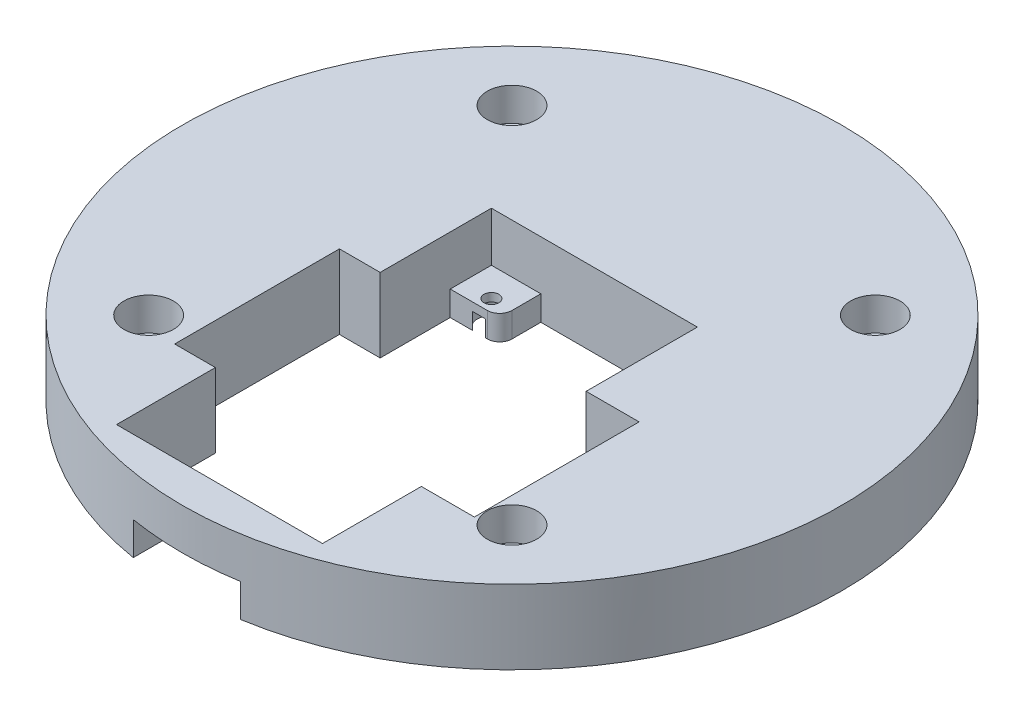
from build123d import *

# Parameters (mm, degrees)
SKETCH1_R                = 40
BOSS_EXTRUDE1_DEPTH      = 8
BOSS_EXTRUDE1_DEPTH_BACK = 1
SKETCH2_W                = 25
SKETCH2_H                = 45.5
CUT_EXTRUDE1_DEPTH       = 6
CUT_EXTRUDE2_DEPTH       = 6
SKETCH4_R                = 3
CUT_EXTRUDE3_DEPTH       = 4
SKETCH5_R                = 1.4
CUT_EXTRUDE4_DEPTH       = 5
CIRPATTERN1_COUNT        = 4
FILLET1_R                = 1.5
SKETCH6_W                = 13
SKETCH6_H                = 8.686825583
CUT_EXTRUDE5_DEPTH       = 4
CUT_EXTRUDE6_START       = -9
SKETCH7_W                = 36.377301766
SKETCH7_H                = 20
CUT_EXTRUDE6_DEPTH       = 9
SKETCH8_R                = 0.9
CUT_EXTRUDE7_DEPTH       = 4
SKETCH9_R                = 1.7
CUT_EXTRUDE10_DEPTH      = 2


with BuildPart() as part:
    # Sketch1 → Boss-Extrude1 (new body, two sides)
    with BuildSketch(Plane(origin=(0, 0, 0), x_dir=(1, 0, 0), z_dir=(0, 1, 0))) as boss_extrude1_sk:
        Circle(SKETCH1_R)
    extrude(amount=BOSS_EXTRUDE1_DEPTH)
    extrude(boss_extrude1_sk.sketch, amount=-BOSS_EXTRUDE1_DEPTH_BACK)

    # Sketch2 → Cut-Extrude1 (cut)
    with BuildSketch(Plane(origin=(0, 8, 0), x_dir=(1, 0, 0), z_dir=(0, 1, 0))):
        with Locations((0, -12.75)):
            Rectangle(SKETCH2_W, SKETCH2_H)
    extrude(amount=-CUT_EXTRUDE1_DEPTH, mode=Mode.SUBTRACT)

    # Sketch3 → Cut-Extrude2 (cut)
    with BuildSketch(Plane(origin=(0, 2, 0), x_dir=(1, 0, 0), z_dir=(0, 1, 0))):
        Polygon((-12.5, 5), (-6.5, 5), (-6.5, 10), (6.5, 10), (6.5, 5), (12.5, 5), (12.5, -30.5), (6.5, -30.5), (6.5, -35.5), (-6.5, -35.5), (-6.5, -30.5), (-12.5, -30.5), align=None)
    extrude(amount=-CUT_EXTRUDE2_DEPTH, mode=Mode.SUBTRACT)

    # Sketch4 → Cut-Extrude3 (cut)
    with BuildSketch(Plane(origin=(0, 8, 0), x_dir=(1, 0, 0), z_dir=(0, 1, 0))):
        with Locations((22.051187962, -22.051187962)):
            Circle(SKETCH4_R)
    cut_extrude3 = extrude(amount=-CUT_EXTRUDE3_DEPTH, mode=Mode.SUBTRACT)

    # Sketch5 → Cut-Extrude4 (cut)
    with BuildSketch(Plane(origin=(0, 4, 0), x_dir=(1, 0, 0), z_dir=(0, 1, 0))):
        with Locations((22.051187962, -22.051187962)):
            Circle(SKETCH5_R)
    cut_extrude4 = extrude(amount=-CUT_EXTRUDE4_DEPTH, mode=Mode.SUBTRACT)

    # CirPattern1: Cut-Extrude3, Cut-Extrude4 ×4 about axis
    cirpattern1_axis = Axis((0, 0, 0), (0, 1, 0))
    for i in range(1, CIRPATTERN1_COUNT):
        add(cut_extrude3.rotate(cirpattern1_axis, i * 360 / CIRPATTERN1_COUNT), mode=Mode.SUBTRACT)
        add(cut_extrude4.rotate(cirpattern1_axis, i * 360 / CIRPATTERN1_COUNT), mode=Mode.SUBTRACT)

    # Fillet1
    fillet1_edges = [part.edges().sort_by_distance(p)[0] for p in [
        (-6.5, 0.5, -5),
        (6.5, 0.5, -5),
        (6.5, 0.5, 30.5),
        (-6.5, 0.5, 30.5),
    ]]
    fillet(fillet1_edges, radius=FILLET1_R)

    # Sketch6 → Cut-Extrude5 (cut)
    with BuildSketch(Plane.XZ.offset(1)):
        with Locations((0, 39.843412792)):
            Rectangle(SKETCH6_W, SKETCH6_H)
    extrude(amount=-CUT_EXTRUDE5_DEPTH, mode=Mode.SUBTRACT)

    # Sketch7 → Cut-Extrude6 (cut)
    with BuildSketch(Plane.XZ.offset(1).offset(CUT_EXTRUDE6_START)):
        with Locations((0.741230287, 13.5)):
            Rectangle(SKETCH7_W, SKETCH7_H)
    extrude(amount=CUT_EXTRUDE6_DEPTH, mode=Mode.SUBTRACT)

    # Sketch8 → Cut-Extrude7 (cut)
    with BuildSketch(Plane(origin=(0, 2, 0), x_dir=(1, 0, 0), z_dir=(0, 1, 0))):
        with Locations((9, -32)):
            Circle(SKETCH8_R)
        with Locations((-9, -32)):
            Circle(SKETCH8_R)
        with Locations((-9, 6.5)):
            Circle(SKETCH8_R)
        with Locations((9, 6.5)):
            Circle(SKETCH8_R)
    extrude(amount=-CUT_EXTRUDE7_DEPTH, mode=Mode.SUBTRACT)

    # Sketch9 → Cut-Extrude10 (cut)
    with BuildSketch(Plane.XZ.offset(1)):
        with Locations((-9, -6.5)):
            Circle(SKETCH9_R)
        with Locations((9, -6.5)):
            Circle(SKETCH9_R)
        with Locations((9, 32)):
            Circle(SKETCH9_R)
        with Locations((-9, 32)):
            Circle(SKETCH9_R)
    extrude(amount=-CUT_EXTRUDE10_DEPTH, mode=Mode.SUBTRACT)


solid = part.part
